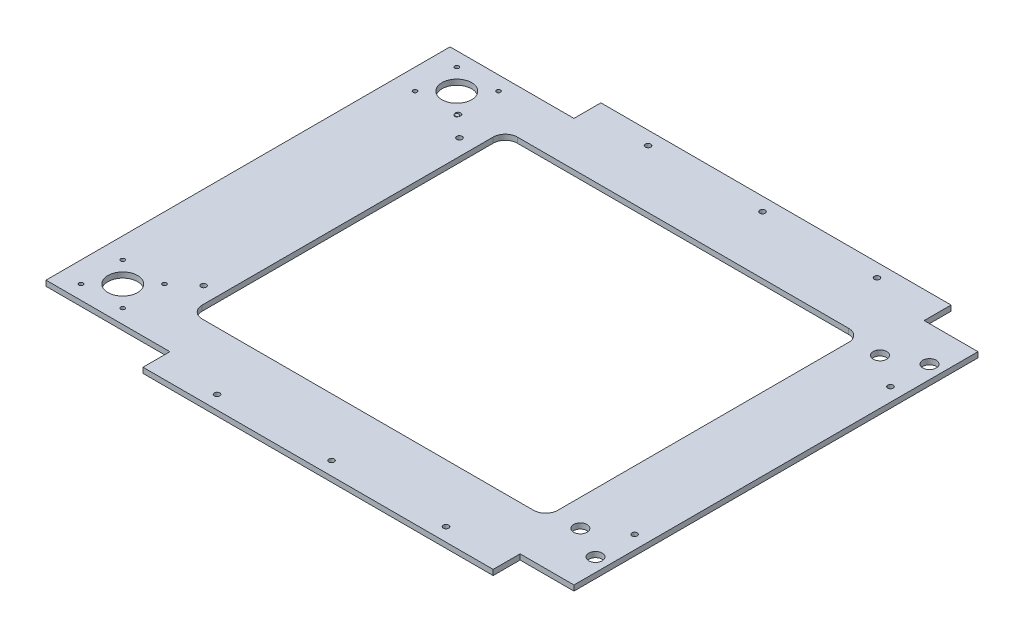
from build123d import *

# Parameters (mm, degrees)
SKETCH1_R             = 5
SKETCH1_R_2           = 2
SKETCH1_R_3           = 1.5
SKETCH1_R_4           = 11
BOSS_EXTRUDE1_DEPTH   = 4
BOSS_EXTRUDE1_2_DEPTH = 4


with BuildPart() as part:
    # Sketch1 → Boss-Extrude1 (new body)
    with BuildSketch(Plane(origin=(0, 0, 0), x_dir=(1, 0, 0), z_dir=(0, 1, 0))):
        Polygon((130, -150), (170, -150), (170, 150), (130, 150), (130, 170), (-130, 170), (-130, 150), (-222, 150), (-222, -150), (-130, -150), (-130, -170), (130, -170), align=None)
        with BuildLine():
            Line((116, 108), (116, -108))
            ThreePointArc((116, -108), (113.363961031, -114.363961031), (107, -117))
            Line((107, -117), (-139, -117))
            ThreePointArc((-139, -117), (-145.363961031, -114.363961031), (-148, -108))
            Line((-148, -108), (-148, 108))
            ThreePointArc((-148, 108), (-145.363961031, 114.363961031), (-139, 117))
            Line((-139, 117), (107, 117))
            ThreePointArc((107, 117), (113.363961031, 114.363961031), (116, 108))
        make_face(mode=Mode.SUBTRACT)
        with Locations((136, -111.25)):
            Circle(SKETCH1_R, mode=Mode.SUBTRACT)
        with Locations((160, -124)):
            Circle(SKETCH1_R, mode=Mode.SUBTRACT)
        with Locations((160, -95)):
            Circle(SKETCH1_R_2, mode=Mode.SUBTRACT)
        with Locations((160, 95)):
            Circle(SKETCH1_R_2, mode=Mode.SUBTRACT)
        with Locations((136, 111.25)):
            Circle(SKETCH1_R, mode=Mode.SUBTRACT)
        with Locations((160, 124)):
            Circle(SKETCH1_R, mode=Mode.SUBTRACT)
        with Locations((85, -160)):
            Circle(SKETCH1_R_2, mode=Mode.SUBTRACT)
        with Locations((-85, -160)):
            Circle(SKETCH1_R_2, mode=Mode.SUBTRACT)
        with Locations((0, -160)):
            Circle(SKETCH1_R_2, mode=Mode.SUBTRACT)
        with Locations((85, 160)):
            Circle(SKETCH1_R_2, mode=Mode.SUBTRACT)
        with Locations((-85, 160)):
            Circle(SKETCH1_R_2, mode=Mode.SUBTRACT)
        with Locations((0, 160)):
            Circle(SKETCH1_R_2, mode=Mode.SUBTRACT)
        with Locations((-160, 95)):
            Circle(SKETCH1_R_2, mode=Mode.SUBTRACT)
        with Locations((-160, -95)):
            Circle(SKETCH1_R_2, mode=Mode.SUBTRACT)
        with Locations((-175.5, -108.5)):
            Circle(SKETCH1_R_3, mode=Mode.SUBTRACT)
        with Locations((-206.5, -139.5)):
            Circle(SKETCH1_R_3, mode=Mode.SUBTRACT)
        with Locations((-175.5, -139.5)):
            Circle(SKETCH1_R_3, mode=Mode.SUBTRACT)
        with Locations((-206.5, -108.5)):
            Circle(SKETCH1_R_3, mode=Mode.SUBTRACT)
        with Locations((-191, -124)):
            Circle(SKETCH1_R_4, mode=Mode.SUBTRACT)
        with Locations((-175.5, 139.5)):
            Circle(SKETCH1_R_3, mode=Mode.SUBTRACT)
        with Locations((-206.5, 139.5)):
            Circle(SKETCH1_R_3, mode=Mode.SUBTRACT)
        with Locations((-206.5, 108.5)):
            Circle(SKETCH1_R_3, mode=Mode.SUBTRACT)
        with Locations((-191, 124)):
            Circle(SKETCH1_R_4, mode=Mode.SUBTRACT)
        with BuildLine():
            ThreePointArc((-174.016466118, 108.278353388), (-175.350744421, 107.007444215), (-176.910266555, 107.988973344))
            ThreePointArc((-176.910266555, 107.988973344), (-175.799007438, 111.49007438), (-174.016466118, 108.278353388))
        make_face(mode=Mode.SUBTRACT)
    extrude(amount=BOSS_EXTRUDE1_DEPTH)


with BuildPart() as body_2:
    # Sketch1 → Boss-Extrude1 2 (new body)
    with BuildSketch(Plane(origin=(0, 0, 0), x_dir=(1, 0, 0), z_dir=(0, 1, 0))):
        with BuildLine():
            ThreePointArc((-174.016466118, 108.278353388), (-175.649255579, 109.992555785), (-176.910266555, 107.988973344))
            ThreePointArc((-176.910266555, 107.988973344), (-175.400992562, 107.50992562), (-174.016466118, 108.278353388))
        make_face()
    extrude(amount=BOSS_EXTRUDE1_2_DEPTH)


solid = Compound([part.part, body_2.part])
